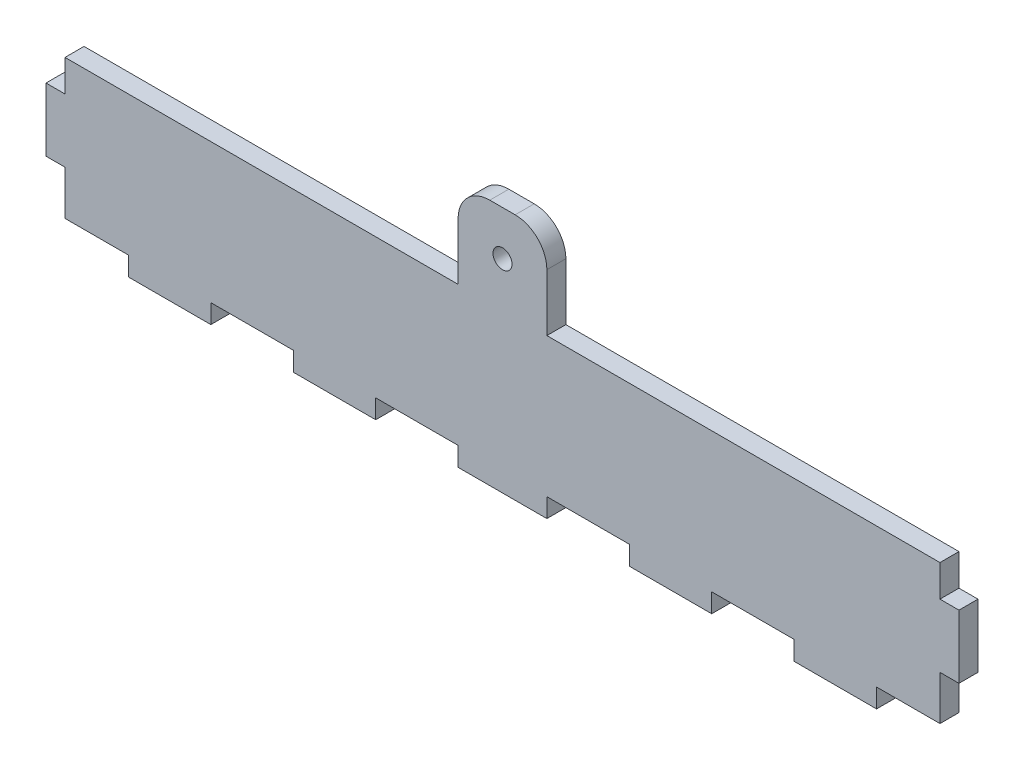
from build123d import *

# Parameters (mm, degrees)
SKETCH1_R           = 1.5
BOSS_EXTRUDE1_DEPTH = 3


with BuildPart() as part:
    # Sketch1 → Boss-Extrude1 (new body)
    with BuildSketch(Plane.XY):
        with BuildLine():
            Line((0, 17), (0, 22))
            Line((0, 22), (62, 22))
            Line((62, 22), (62, 31))
            ThreePointArc((62, 31), (63.464466094, 34.535533906), (67, 36))
            Line((67, 36), (71, 36))
            ThreePointArc((71, 36), (74.535533906, 34.535533906), (76, 31))
            Line((76, 31), (76, 22))
            Line((76, 22), (138, 22))
            Line((138, 22), (138, 17))
            Line((138, 17), (141, 17))
            Line((141, 17), (141, 7))
            Line((141, 7), (138, 7))
            Line((138, 7), (138, 0))
            Line((138, 0), (128, 0))
            Line((128, 0), (128, -3))
            Line((128, -3), (115, -3))
            Line((115, -3), (115, 0))
            Line((115, 0), (102, 0))
            Line((102, 0), (102, -3))
            Line((102, -3), (89, -3))
            Line((89, -3), (89, 0))
            Line((89, 0), (76, 0))
            Line((76, 0), (76, -3))
            Line((76, -3), (62, -3))
            Line((62, -3), (62, 0))
            Line((62, 0), (49, 0))
            Line((49, 0), (49, -3))
            Line((49, -3), (36, -3))
            Line((36, -3), (36, 0))
            Line((36, 0), (23, 0))
            Line((23, 0), (23, -3))
            Line((23, -3), (10, -3))
            Line((10, -3), (10, 0))
            Line((10, 0), (0, 0))
            Line((0, 0), (0, 7))
            Line((0, 7), (-3, 7))
            Line((-3, 7), (-3, 17))
            Line((-3, 17), (0, 17))
        make_face()
        with Locations((69, 29)):
            Circle(SKETCH1_R, mode=Mode.SUBTRACT)
    extrude(amount=BOSS_EXTRUDE1_DEPTH)


solid = part.part
